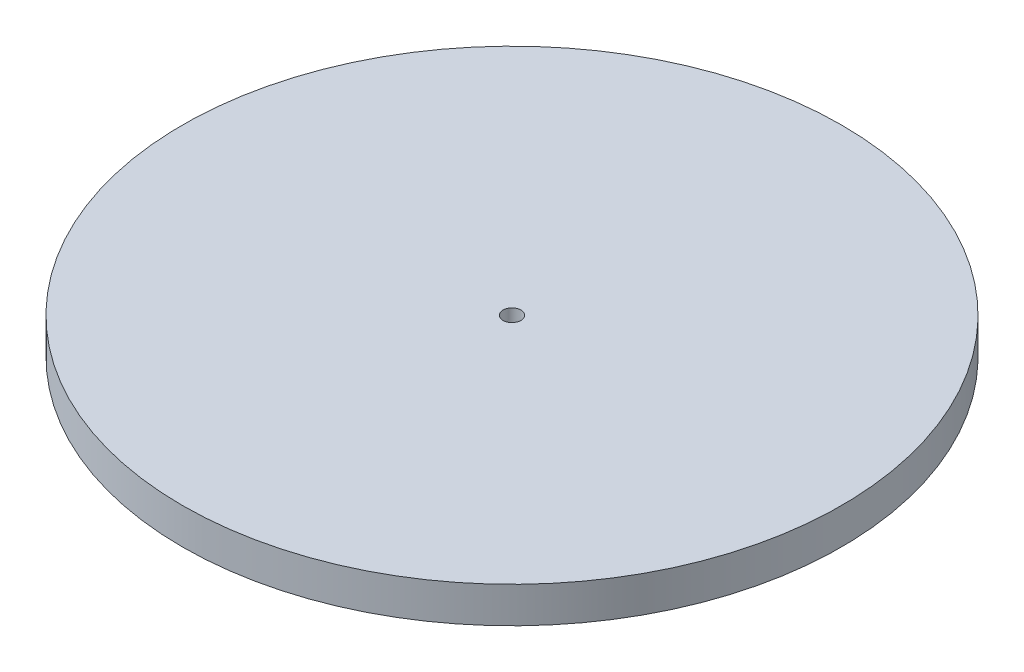
from build123d import *

# Parameters (mm, degrees)
SKETCH1_R           = 27.5
SKETCH1_R_2         = 0.75
BOSS_EXTRUDE1_DEPTH = 3


with BuildPart() as part:
    # Sketch1 → Boss-Extrude1 (new body)
    with BuildSketch(Plane(origin=(0, 0, 0), x_dir=(1, 0, 0), z_dir=(0, 1, 0))):
        Circle(SKETCH1_R)
        Circle(SKETCH1_R_2, mode=Mode.SUBTRACT)
    extrude(amount=BOSS_EXTRUDE1_DEPTH)


solid = part.part
